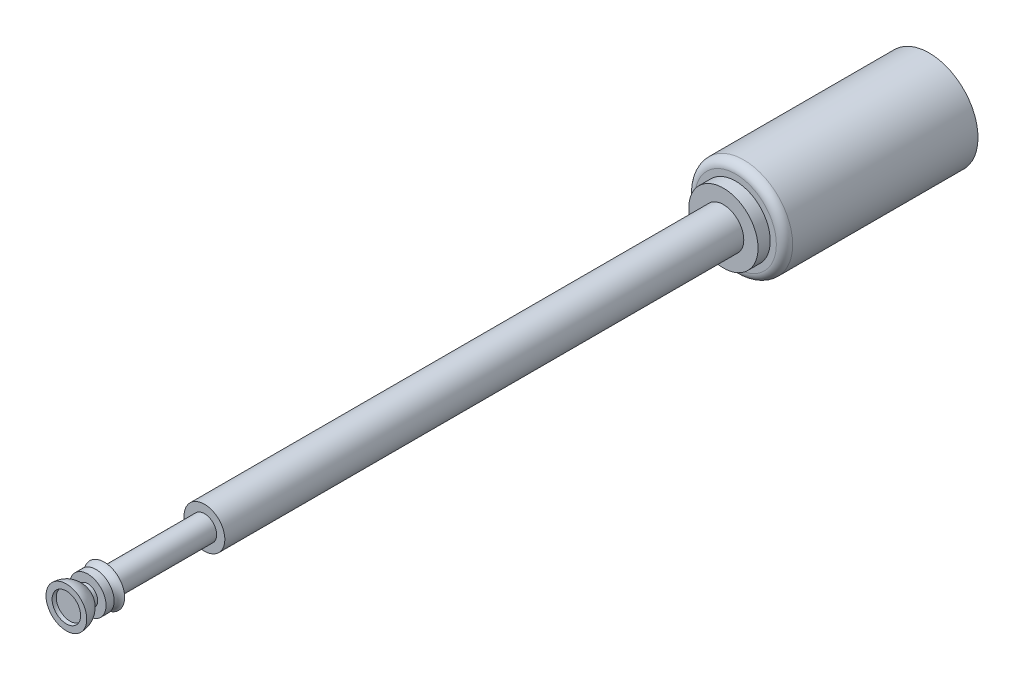
from build123d import *

# Parameters (mm, degrees)
SKETCH1_R           = 0.5
BOSS_EXTRUDE1_DEPTH = 15.5
SKETCH1_3_R         = 1.2
BOSS_EXTRUDE2_DEPTH = 4.75
FILLET1_R           = 0.2
SKETCH2_R           = 0.85
BOSS_EXTRUDE3_DEPTH = 0.3
SKETCH4_W           = 0.461524445
SKETCH4_H           = 0.045344169
SKETCH7_W           = 0.600727217
SKETCH7_H           = 2.46


with BuildPart() as part:
    # Sketch1 → Boss-Extrude1 (new body)
    with BuildSketch(Plane.XY):
        Circle(SKETCH1_R)
    extrude(amount=BOSS_EXTRUDE1_DEPTH)



with BuildPart() as body_2:
    # Sketch1_3 → Boss-Extrude2 (new body)
    with BuildSketch(Plane.XY):
        Circle(SKETCH1_3_R)
    extrude(amount=-BOSS_EXTRUDE2_DEPTH)

    # Fillet1
    fillet1_edges = [body_2.edges().sort_by_distance(p)[0] for p in [
        (-1.2, 0, 0),
    ]]
    fillet(fillet1_edges, radius=FILLET1_R)


with BuildPart() as part_1:
    add(part.part)

    add(body_2.part)  # Boss-Extrude3 merges body 2
    # Sketch2 → Boss-Extrude3 (add)
    with BuildSketch(Plane.XY):
        Circle(SKETCH2_R)
    extrude(amount=BOSS_EXTRUDE3_DEPTH)

    # Sketch3 → Revolve1 (revolve)
    with BuildSketch(Plane(origin=(0, 0, 0), x_dir=(1, 0, 0), z_dir=(0, 1, 0))):
        with BuildLine():
            Line((0.5, -15.5), (0, -15.5))
            Line((0, -15.5), (0, -16.08))
            ThreePointArc((0, -16.08), (0.247487373, -16.182512627), (0.35, -16.43))
            Line((0.35, -16.43), (0.5, -16.43))
            ThreePointArc((0.5, -16.43), (0.430997893, -16.176542279), (0.243036734, -15.993041025))
            Line((0.243036734, -15.993041025), (0.243036734, -15.903342272))
            Line((0.243036734, -15.903342272), (0.447644951, -15.903342272))
            Line((0.447644951, -15.903342272), (0.447644951, -15.705896244))
            Line((0.447644951, -15.705896244), (0.36945341, -15.705896244))
            ThreePointArc((0.36945341, -15.705896244), (0.404840541, -15.583999079), (0.5, -15.5))
        make_face()
    revolve(axis=Axis((0, 0, 15.5), (0, 0, 1)))

    # Sketch4 → Revolve2 (revolve)
    with BuildSketch(Plane(origin=(0, 0, 0), x_dir=(1, 0, 0), z_dir=(0, 1, 0))):
        with Locations((-0.230762223, -16.317327916)):
            Rectangle(SKETCH4_W, SKETCH4_H)
    revolve(axis=Axis((0, 0, 15.5), (0, 0, 1)))

    # Sketch7 → Cut-Revolve1 (revolve, cut)
    with BuildSketch(Plane(origin=(0, 0, 0), x_dir=(1, 0, 0), z_dir=(0, 1, 0))):
        with Locations((-0.600363609, -14.27)):
            Rectangle(SKETCH7_W, SKETCH7_H)
    revolve(axis=Axis((0, 0, 15.5), (0, 0, 1)), mode=Mode.SUBTRACT)


solid = part_1.part
